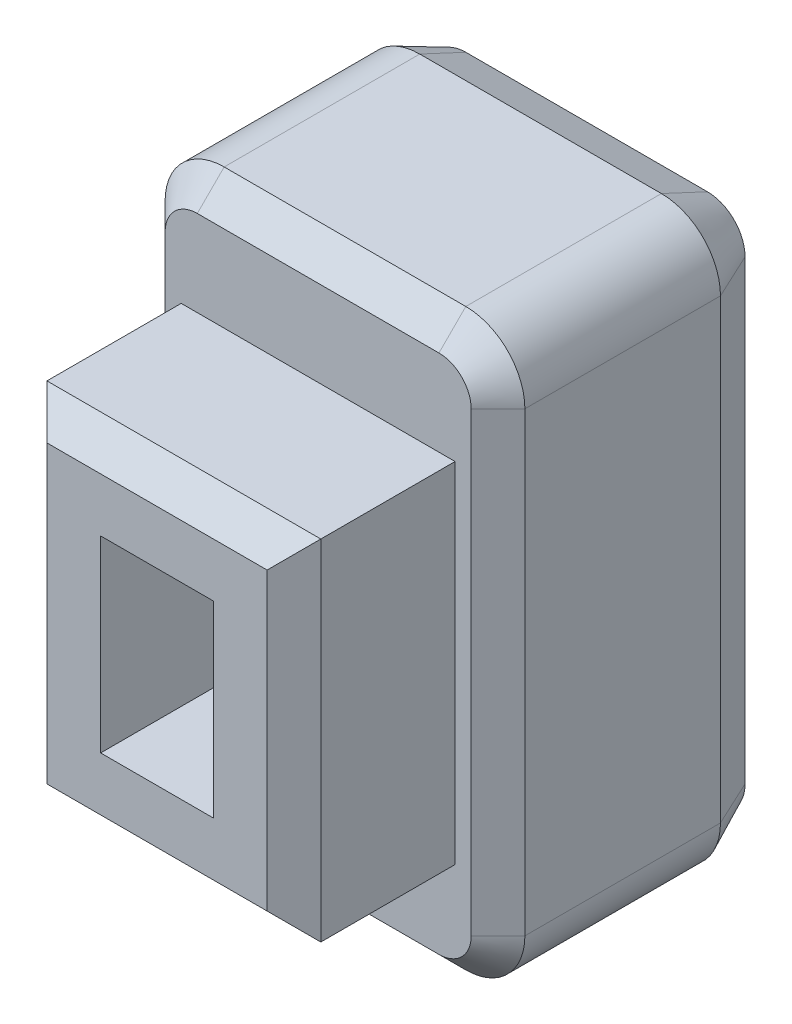
from build123d import *

# Parameters (mm, degrees)
BOSS_EXTRU_1_DEPTH      = 8
CHANFREIN1_SIZE         = 0.4
CHANFREIN1_SIZE2        = 0.857802768
ESQUISSE3_W             = 2.1
ESQUISSE3_H             = 3.5
ENL_V_MAT_EXTRU_4_DEPTH = 3
ESQUISSE4_OUTSIDE_W     = 11.69
ESQUISSE4_OUTSIDE_H     = 15.69
ESQUISSE4_OUTSIDE_W_2   = 5.1
ESQUISSE4_OUTSIDE_H_2   = 6.5
ENL_V_MAT_EXTRU_5_DEPTH = 3
CHANFREIN2_SIZE         = 0.5
BOSS_EXTRU_2_DEPTH      = 0.2
ENL_V_MAT_EXTRU_6_DEPTH = 0.2


with BuildPart() as part:
    # Esquisse2 → Boss.-Extru.1 (new body)
    with BuildSketch(Plane.XY):
        with BuildLine():
            Line((1.1, 0), (5.6, 0))
            ThreePointArc((5.6, 0), (6.377817459, 0.322182541), (6.7, 1.1))
            Line((6.7, 1.1), (6.7, 9.6))
            ThreePointArc((6.7, 9.6), (6.377817459, 10.377817459), (5.6, 10.7))
            Line((5.6, 10.7), (1.1, 10.7))
            ThreePointArc((1.1, 10.7), (0.322182541, 10.377817459), (0, 9.6))
            Line((0, 9.6), (0, 1.1))
            ThreePointArc((0, 1.1), (0.322182541, 0.322182541), (1.1, 0))
        make_face()
    extrude(amount=BOSS_EXTRU_1_DEPTH)

    # Chanfrein1
    chanfrein1_edges = [part.edges().sort_by_distance(p)[0] for p in [
        (3.35, 0, 0),
        (6.377817459, 0.322182541, 0),
        (0.322182541, 0.322182541, 0),
        (6.7, 5.35, 0),
        (0, 5.35, 0),
        (6.377817459, 10.377817459, 0),
        (0.322182541, 10.377817459, 0),
        (3.35, 10.7, 0),
    ]]
    chanfrein1_side = [part.faces().sort_by_distance(p)[0] for p in [
        (3.35, 5.35, 0),
    ]]
    chamfer(chanfrein1_edges, length=CHANFREIN1_SIZE, length2=CHANFREIN1_SIZE2, reference=chanfrein1_side[0])

    # Esquisse3 → Enl_v. mat.-Extru.4 (cut)
    with BuildSketch(Plane.XY.offset(8)):
        with Locations((3.35, 5.35)):
            Rectangle(ESQUISSE3_W, ESQUISSE3_H)
    extrude(amount=-ENL_V_MAT_EXTRU_4_DEPTH, mode=Mode.SUBTRACT)

    # Esquisse4 outside → Enl_v. mat.-Extru.5 (cut)
    with BuildSketch(Plane.XY.offset(8)):
        with Locations((3.35, 5.35)):
            Rectangle(ESQUISSE4_OUTSIDE_W, ESQUISSE4_OUTSIDE_H)
        with Locations((3.35, 5.35)):
            Rectangle(ESQUISSE4_OUTSIDE_W_2, ESQUISSE4_OUTSIDE_H_2, mode=Mode.SUBTRACT)
    extrude(amount=-ENL_V_MAT_EXTRU_5_DEPTH, mode=Mode.SUBTRACT)

    # Chanfrein2
    chanfrein2_edges = [part.edges().sort_by_distance(p)[0] for p in [
        (6.7, 5.35, 5),
        (6.377817459, 10.377817459, 5),
        (6.377817459, 0.322182541, 5),
        (3.35, 10.7, 5),
        (3.35, 0, 5),
        (0.322182541, 10.377817459, 5),
        (0.322182541, 0.322182541, 5),
        (0, 5.35, 5),
        (5.9, 5.35, 8),
        (3.35, 8.6, 8),
        (0.8, 5.35, 8),
        (3.35, 2.1, 8),
    ]]
    chamfer(chanfrein2_edges, length=CHANFREIN2_SIZE)

    # Esquisse5 → Boss.-Extru.2 (add)
    with BuildSketch(Plane(origin=(0, 0, 0), x_dir=(-1, 0, 0), z_dir=(0, 0, -1))):
        Polygon((-3.375, 5.112187571), (-2.775, 6.112187571), (-3.175, 6.112187571), (-3.175, 8.848759861), (-2.775, 8.848759861), (-3.375, 9.848759861), (-3.975, 8.848759861), (-3.575, 8.848759861), (-3.575, 6.112187571), (-4.005, 6.112187571), align=None)
        with BuildLine():
            Line((-4.920512821, 1.614669586), (-4.459875801, 2.054974073))
            add(Edge.make_bspline(
                [(-4.459875801, 2.054974073), (-4.420846299, 2.014511582), (-4.34448535, 1.935347003), (-4.220854035, 1.831711948), (-4.09375597, 1.743635159), (-3.962835409, 1.671846315), (-3.828167562, 1.614874111), (-3.689518129, 1.575130326), (-3.547222024, 1.550105285), (-3.451064686, 1.547349207), (-3.402584135, 1.54595965)],
                knots=[0, 0, 0, 0, 1.115370381, 2.182214363, 3.196266025, 4.180416361, 5.141116029, 6.092551847, 7.038303877, 8, 8, 8, 8], degree=3))
            add(Edge.make_bspline(
                [(-3.402584135, 1.54595965), (-3.362102363, 1.547078973), (-3.282216047, 1.549287833), (-3.164933085, 1.565519982), (-3.052703334, 1.593019341), (-2.945437754, 1.631243249), (-2.842606012, 1.679379967), (-2.745165655, 1.73988435), (-2.652593027, 1.810736992), (-2.565969764, 1.891813909), (-2.487767695, 1.981051873), (-2.417306519, 2.075035445), (-2.358944017, 2.175426967), (-2.311302773, 2.280762425), (-2.273760377, 2.391079854), (-2.247115032, 2.506373733), (-2.231676701, 2.626904375), (-2.229374947, 2.708843181), (-2.228205128, 2.750486893)],
                knots=[0, 0, 0, 0, 1.035268443, 2.04298821, 3.02163646, 3.985902049, 4.951223231, 5.920091634, 6.913651787, 7.92868536, 8.949353712, 9.945284791, 10.92850487, 11.913014323, 12.897904816, 13.904240668, 14.934873455, 16, 16, 16, 16], degree=3))
            add(Edge.make_bspline(
                [(-2.228205128, 2.750486893), (-2.228547069, 2.779714506), (-2.229221042, 2.837322732), (-2.236412733, 2.922322339), (-2.248356392, 3.004970387), (-2.265108318, 3.085022003), (-2.286197567, 3.16282251), (-2.3120088, 3.237865153), (-2.34321706, 3.310246212), (-2.378144287, 3.380344841), (-2.417130534, 3.447567062), (-2.460832328, 3.51102144), (-2.508759959, 3.570214906), (-2.558995672, 3.627207188), (-2.614866466, 3.678663011), (-2.673870809, 3.72741818), (-2.736855301, 3.772264854), (-2.803743453, 3.812578931), (-2.87253873, 3.850150951), (-2.944650853, 3.881265423), (-3.018064727, 3.909235481), (-3.094068279, 3.93027738), (-3.17132271, 3.948579384), (-3.250903329, 3.959756987), (-3.332054887, 3.968250487), (-3.386902133, 3.968773416), (-3.414503205, 3.969036573)],
                knots=[0, 0, 0, 0, 1.103833241, 2.175677997, 3.219414644, 4.256521947, 5.263082927, 6.262573145, 7.25136242, 8.238376666, 9.219530388, 10.184343756, 11.145312504, 12.095474572, 13.051075647, 14.010745898, 14.985684176, 15.968306307, 16.959653902, 17.943861036, 18.93268972, 19.924626761, 20.920484516, 21.929288403, 22.957944781, 24, 24, 24, 24], degree=3))
            add(Edge.make_bspline(
                [(-3.414503205, 3.969036573), (-3.461320183, 3.967685471), (-3.553303371, 3.965030909), (-3.688282033, 3.94418198), (-3.817273546, 3.910041016), (-3.920135017, 3.86897613), (-4.00061923, 3.829055195), (-4.061859205, 3.792658055), (-4.124918626, 3.751430354), (-4.189365745, 3.704230017), (-4.255549419, 3.651618753), (-4.322332669, 3.592496918), (-4.39141598, 3.528796149), (-4.436672134, 3.483332304), (-4.459875801, 3.46002215)],
                knots=[0, 0, 0, 0, 1.404640003, 2.759752344, 4.088613405, 5.401587939, 6.076032573, 6.783413463, 7.538272532, 8.336594406, 9.180107851, 10.074881764, 11.012956238, 12, 12, 12, 12], degree=3))
            Line((-4.459875801, 3.46002215), (-4.906490385, 3.92907263))
            add(Edge.make_bspline(
                [(-4.906490385, 3.92907263), (-4.875095784, 3.959383134), (-4.813820237, 4.018542754), (-4.721387769, 4.102543873), (-4.629071655, 4.178028292), (-4.539101951, 4.247735418), (-4.450005243, 4.3096357), (-4.361789653, 4.363786819), (-4.275458434, 4.411572832), (-4.189202666, 4.45213752), (-4.102337645, 4.486800979), (-4.013000336, 4.516034428), (-3.921148052, 4.541553225), (-3.82602007, 4.561635202), (-3.72804084, 4.577983321), (-3.626895522, 4.588785799), (-3.523056698, 4.596276637), (-3.452845044, 4.596917388), (-3.417307692, 4.597241701)],
                knots=[0, 0, 0, 0, 1.244537013, 2.429070097, 3.56066612, 4.644477994, 5.67429546, 6.652817684, 7.595405349, 8.486886006, 9.369351459, 10.26090686, 11.166404474, 12.086719576, 13.0323422, 13.998023148, 14.9867073, 16, 16, 16, 16], degree=3))
            add(Edge.make_bspline(
                [(-3.417307692, 4.597241701), (-3.352032495, 4.595574765), (-3.224307077, 4.592313035), (-3.037110762, 4.568229021), (-2.859131754, 4.52758602), (-2.690050251, 4.470886492), (-2.530383713, 4.397262458), (-2.379631423, 4.307928151), (-2.238044431, 4.202035693), (-2.106841078, 4.081162784), (-1.988198588, 3.94764072), (-1.883213819, 3.80432959), (-1.796752371, 3.650200241), (-1.723394275, 3.488554223), (-1.668423526, 3.316864385), (-1.628409666, 3.136682142), (-1.604061441, 2.94723427), (-1.601371757, 2.817867188), (-1.6, 2.751889137)],
                knots=[0, 0, 0, 0, 1.07798487, 2.109316747, 3.111276023, 4.08905949, 5.049398091, 6.009992678, 6.978127636, 7.964347882, 8.951383687, 9.924270623, 10.892397886, 11.86520058, 12.851549246, 13.863953586, 14.910602472, 16, 16, 16, 16], degree=3))
            add(Edge.make_bspline(
                [(-1.6, 2.751889137), (-1.60059911, 2.708860645), (-1.601786399, 2.623588692), (-1.613491091, 2.497650452), (-1.6314466, 2.37539273), (-1.657001505, 2.256965891), (-1.688775638, 2.14195989), (-1.729219515, 2.030895436), (-1.776063909, 1.923164525), (-1.830754233, 1.819771117), (-1.892059168, 1.720584556), (-1.95908204, 1.625855552), (-2.033113492, 1.536526332), (-2.113450018, 1.452206195), (-2.199423946, 1.372350154), (-2.291876094, 1.297524954), (-2.390894864, 1.228213126), (-2.495470232, 1.164357704), (-2.603611311, 1.105715314), (-2.715394958, 1.056543815), (-2.828642724, 1.013137307), (-2.944121927, 0.978076922), (-3.062086738, 0.951630786), (-3.181636352, 0.931673682), (-3.30374757, 0.920504132), (-3.385736125, 0.918676897), (-3.427123397, 0.917754521)],
                knots=[0, 0, 0, 0, 1.07193642, 2.124315995, 3.14887099, 4.149444713, 5.141371803, 6.119544533, 7.092241254, 8.06650569, 9.031360777, 9.996057679, 10.955696533, 11.919602115, 12.89624813, 13.877605408, 14.880920851, 15.905674436, 16.929600311, 17.943674756, 18.946313929, 19.950355855, 20.947755382, 21.956851243, 22.968632213, 24, 24, 24, 24], degree=3))
            add(Edge.make_bspline(
                [(-3.427123397, 0.917754521), (-3.462430717, 0.918283914), (-3.532678258, 0.919337196), (-3.637291519, 0.928101928), (-3.741056679, 0.941905932), (-3.843656874, 0.962587697), (-3.94555349, 0.987634266), (-4.046319913, 1.018484878), (-4.145678277, 1.056115394), (-4.24448994, 1.097742685), (-4.340784252, 1.145133196), (-4.433724348, 1.198177586), (-4.523540518, 1.255488164), (-4.60969132, 1.318050681), (-4.692783551, 1.384946175), (-4.772728553, 1.456172431), (-4.848759193, 1.533021476), (-4.89647403, 1.587315961), (-4.920512821, 1.614669586)],
                knots=[0, 0, 0, 0, 0.996333415, 1.982307736, 2.96084097, 3.949129141, 4.93457382, 5.921430247, 6.92116383, 7.931890485, 8.946633814, 9.948019707, 10.950686436, 11.952094051, 12.951305284, 13.960287133, 14.972390273, 16, 16, 16, 16], degree=3))
        make_face()
    extrude(amount=BOSS_EXTRU_2_DEPTH)

    # Esquisse5_2 → Enl_v. mat.-Extru.6 (cut)
    with BuildSketch(Plane(origin=(0, 0, 0), x_dir=(-1, 0, 0), z_dir=(0, 0, -1))):
        Polygon((-3.375, 5.112187571), (-2.775, 6.112187571), (-3.175, 6.112187571), (-3.175, 8.848759861), (-2.775, 8.848759861), (-3.375, 9.848759861), (-3.975, 8.848759861), (-3.575, 8.848759861), (-3.575, 6.112187571), (-4.005, 6.112187571), align=None)
        with BuildLine():
            Line((-4.920512821, 1.614669586), (-4.459875801, 2.054974073))
            add(Edge.make_bspline(
                [(-4.459875801, 2.054974073), (-4.420846299, 2.014511582), (-4.34448535, 1.935347003), (-4.220854035, 1.831711948), (-4.09375597, 1.743635159), (-3.962835409, 1.671846315), (-3.828167562, 1.614874111), (-3.689518129, 1.575130326), (-3.547222024, 1.550105285), (-3.451064686, 1.547349207), (-3.402584135, 1.54595965)],
                knots=[0, 0, 0, 0, 1.115370381, 2.182214363, 3.196266025, 4.180416361, 5.141116029, 6.092551847, 7.038303877, 8, 8, 8, 8], degree=3))
            add(Edge.make_bspline(
                [(-3.402584135, 1.54595965), (-3.362102363, 1.547078973), (-3.282216047, 1.549287833), (-3.164933085, 1.565519982), (-3.052703334, 1.593019341), (-2.945437754, 1.631243249), (-2.842606012, 1.679379967), (-2.745165655, 1.73988435), (-2.652593027, 1.810736992), (-2.565969764, 1.891813909), (-2.487767695, 1.981051873), (-2.417306519, 2.075035445), (-2.358944017, 2.175426967), (-2.311302773, 2.280762425), (-2.273760377, 2.391079854), (-2.247115032, 2.506373733), (-2.231676701, 2.626904375), (-2.229374947, 2.708843181), (-2.228205128, 2.750486893)],
                knots=[0, 0, 0, 0, 1.035268443, 2.04298821, 3.02163646, 3.985902049, 4.951223231, 5.920091634, 6.913651787, 7.92868536, 8.949353712, 9.945284791, 10.92850487, 11.913014323, 12.897904816, 13.904240668, 14.934873455, 16, 16, 16, 16], degree=3))
            add(Edge.make_bspline(
                [(-2.228205128, 2.750486893), (-2.228547069, 2.779714506), (-2.229221042, 2.837322732), (-2.236412733, 2.922322339), (-2.248356392, 3.004970387), (-2.265108318, 3.085022003), (-2.286197567, 3.16282251), (-2.3120088, 3.237865153), (-2.34321706, 3.310246212), (-2.378144287, 3.380344841), (-2.417130534, 3.447567062), (-2.460832328, 3.51102144), (-2.508759959, 3.570214906), (-2.558995672, 3.627207188), (-2.614866466, 3.678663011), (-2.673870809, 3.72741818), (-2.736855301, 3.772264854), (-2.803743453, 3.812578931), (-2.87253873, 3.850150951), (-2.944650853, 3.881265423), (-3.018064727, 3.909235481), (-3.094068279, 3.93027738), (-3.17132271, 3.948579384), (-3.250903329, 3.959756987), (-3.332054887, 3.968250487), (-3.386902133, 3.968773416), (-3.414503205, 3.969036573)],
                knots=[0, 0, 0, 0, 1.103833241, 2.175677997, 3.219414644, 4.256521947, 5.263082927, 6.262573145, 7.25136242, 8.238376666, 9.219530388, 10.184343756, 11.145312504, 12.095474572, 13.051075647, 14.010745898, 14.985684176, 15.968306307, 16.959653902, 17.943861036, 18.93268972, 19.924626761, 20.920484516, 21.929288403, 22.957944781, 24, 24, 24, 24], degree=3))
            add(Edge.make_bspline(
                [(-3.414503205, 3.969036573), (-3.461320183, 3.967685471), (-3.553303371, 3.965030909), (-3.688282033, 3.94418198), (-3.817273546, 3.910041016), (-3.920135017, 3.86897613), (-4.00061923, 3.829055195), (-4.061859205, 3.792658055), (-4.124918626, 3.751430354), (-4.189365745, 3.704230017), (-4.255549419, 3.651618753), (-4.322332669, 3.592496918), (-4.39141598, 3.528796149), (-4.436672134, 3.483332304), (-4.459875801, 3.46002215)],
                knots=[0, 0, 0, 0, 1.404640003, 2.759752344, 4.088613405, 5.401587939, 6.076032573, 6.783413463, 7.538272532, 8.336594406, 9.180107851, 10.074881764, 11.012956238, 12, 12, 12, 12], degree=3))
            Line((-4.459875801, 3.46002215), (-4.906490385, 3.92907263))
            add(Edge.make_bspline(
                [(-4.906490385, 3.92907263), (-4.875095784, 3.959383134), (-4.813820237, 4.018542754), (-4.721387769, 4.102543873), (-4.629071655, 4.178028292), (-4.539101951, 4.247735418), (-4.450005243, 4.3096357), (-4.361789653, 4.363786819), (-4.275458434, 4.411572832), (-4.189202666, 4.45213752), (-4.102337645, 4.486800979), (-4.013000336, 4.516034428), (-3.921148052, 4.541553225), (-3.82602007, 4.561635202), (-3.72804084, 4.577983321), (-3.626895522, 4.588785799), (-3.523056698, 4.596276637), (-3.452845044, 4.596917388), (-3.417307692, 4.597241701)],
                knots=[0, 0, 0, 0, 1.244537013, 2.429070097, 3.56066612, 4.644477994, 5.67429546, 6.652817684, 7.595405349, 8.486886006, 9.369351459, 10.26090686, 11.166404474, 12.086719576, 13.0323422, 13.998023148, 14.9867073, 16, 16, 16, 16], degree=3))
            add(Edge.make_bspline(
                [(-3.417307692, 4.597241701), (-3.352032495, 4.595574765), (-3.224307077, 4.592313035), (-3.037110762, 4.568229021), (-2.859131754, 4.52758602), (-2.690050251, 4.470886492), (-2.530383713, 4.397262458), (-2.379631423, 4.307928151), (-2.238044431, 4.202035693), (-2.106841078, 4.081162784), (-1.988198588, 3.94764072), (-1.883213819, 3.80432959), (-1.796752371, 3.650200241), (-1.723394275, 3.488554223), (-1.668423526, 3.316864385), (-1.628409666, 3.136682142), (-1.604061441, 2.94723427), (-1.601371757, 2.817867188), (-1.6, 2.751889137)],
                knots=[0, 0, 0, 0, 1.07798487, 2.109316747, 3.111276023, 4.08905949, 5.049398091, 6.009992678, 6.978127636, 7.964347882, 8.951383687, 9.924270623, 10.892397886, 11.86520058, 12.851549246, 13.863953586, 14.910602472, 16, 16, 16, 16], degree=3))
            add(Edge.make_bspline(
                [(-1.6, 2.751889137), (-1.60059911, 2.708860645), (-1.601786399, 2.623588692), (-1.613491091, 2.497650452), (-1.6314466, 2.37539273), (-1.657001505, 2.256965891), (-1.688775638, 2.14195989), (-1.729219515, 2.030895436), (-1.776063909, 1.923164525), (-1.830754233, 1.819771117), (-1.892059168, 1.720584556), (-1.95908204, 1.625855552), (-2.033113492, 1.536526332), (-2.113450018, 1.452206195), (-2.199423946, 1.372350154), (-2.291876094, 1.297524954), (-2.390894864, 1.228213126), (-2.495470232, 1.164357704), (-2.603611311, 1.105715314), (-2.715394958, 1.056543815), (-2.828642724, 1.013137307), (-2.944121927, 0.978076922), (-3.062086738, 0.951630786), (-3.181636352, 0.931673682), (-3.30374757, 0.920504132), (-3.385736125, 0.918676897), (-3.427123397, 0.917754521)],
                knots=[0, 0, 0, 0, 1.07193642, 2.124315995, 3.14887099, 4.149444713, 5.141371803, 6.119544533, 7.092241254, 8.06650569, 9.031360777, 9.996057679, 10.955696533, 11.919602115, 12.89624813, 13.877605408, 14.880920851, 15.905674436, 16.929600311, 17.943674756, 18.946313929, 19.950355855, 20.947755382, 21.956851243, 22.968632213, 24, 24, 24, 24], degree=3))
            add(Edge.make_bspline(
                [(-3.427123397, 0.917754521), (-3.462430717, 0.918283914), (-3.532678258, 0.919337196), (-3.637291519, 0.928101928), (-3.741056679, 0.941905932), (-3.843656874, 0.962587697), (-3.94555349, 0.987634266), (-4.046319913, 1.018484878), (-4.145678277, 1.056115394), (-4.24448994, 1.097742685), (-4.340784252, 1.145133196), (-4.433724348, 1.198177586), (-4.523540518, 1.255488164), (-4.60969132, 1.318050681), (-4.692783551, 1.384946175), (-4.772728553, 1.456172431), (-4.848759193, 1.533021476), (-4.89647403, 1.587315961), (-4.920512821, 1.614669586)],
                knots=[0, 0, 0, 0, 0.996333415, 1.982307736, 2.96084097, 3.949129141, 4.93457382, 5.921430247, 6.92116383, 7.931890485, 8.946633814, 9.948019707, 10.950686436, 11.952094051, 12.951305284, 13.960287133, 14.972390273, 16, 16, 16, 16], degree=3))
        make_face()
    extrude(amount=-ENL_V_MAT_EXTRU_6_DEPTH, mode=Mode.SUBTRACT)


with BuildPart() as enl_v_mat_extru_6_piece_1:
    # of the separate pieces the step leaves, piece 1, a body of its own (enl_v_mat_extru_6_pieces)
    add(part.part.solids().sort_by_distance((0, 1.1, 4.5))[0])


with BuildPart() as enl_v_mat_extru_6_piece_2:
    # of the separate pieces the step leaves, piece 2, a body of its own (enl_v_mat_extru_6_pieces)
    add(part.part.solids().sort_by_distance((4.920512821, 1.614669586, -0.2))[0])


with BuildPart() as enl_v_mat_extru_6_piece_3:
    # of the separate pieces the step leaves, piece 3, a body of its own (enl_v_mat_extru_6_pieces)
    add(part.part.solids().sort_by_distance((4.005, 6.112187571, -0.2))[0])


solid = Compound([enl_v_mat_extru_6_piece_1.part, enl_v_mat_extru_6_piece_2.part, enl_v_mat_extru_6_piece_3.part])
